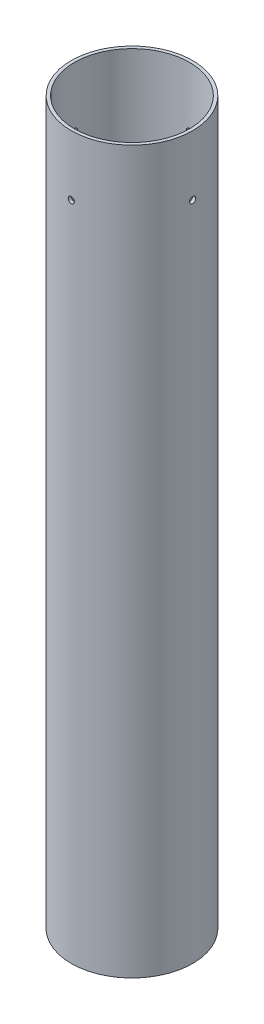
from build123d import *

# Parameters (mm, degrees)
SKETCH1_R               = 38.5
SKETCH1_R_2             = 36.5
BOSS_EXTRUDE1_DEPTH     = 457.2
SKETCH2_R               = 1.95
CUT_EXTRUDE1_DEPTH      = 39.5
CUT_EXTRUDE1_DEPTH_BACK = 39.5
SKETCH3_R               = 1.95
CUT_EXTRUDE2_DEPTH      = 39.5000001
CUT_EXTRUDE2_DEPTH_BACK = 39.5000001


with BuildPart() as part:
    # Sketch1 → Boss-Extrude1 (new body)
    with BuildSketch(Plane(origin=(0, 0, 0), x_dir=(1, 0, 0), z_dir=(0, 1, 0))):
        Circle(SKETCH1_R)
        Circle(SKETCH1_R_2, mode=Mode.SUBTRACT)
    extrude(amount=BOSS_EXTRUDE1_DEPTH)

    # Sketch2 → Cut-Extrude1 (cut, two sides)
    with BuildSketch(Plane(origin=(0, 0, 0), x_dir=(0, 0, -1), z_dir=(1, 0, 0))) as cut_extrude1_sk:
        with Locations((0, 419.1)):
            Circle(SKETCH2_R)
    extrude(amount=CUT_EXTRUDE1_DEPTH, mode=Mode.SUBTRACT)
    extrude(cut_extrude1_sk.sketch, amount=-CUT_EXTRUDE1_DEPTH_BACK, mode=Mode.SUBTRACT)

    # Sketch3 → Cut-Extrude2 (cut, two sides)
    with BuildSketch(Plane.XY) as cut_extrude2_sk:
        with Locations((0, 419.1)):
            Circle(SKETCH3_R)
    extrude(amount=CUT_EXTRUDE2_DEPTH, mode=Mode.SUBTRACT)
    extrude(cut_extrude2_sk.sketch, amount=-CUT_EXTRUDE2_DEPTH_BACK, mode=Mode.SUBTRACT)


solid = part.part
